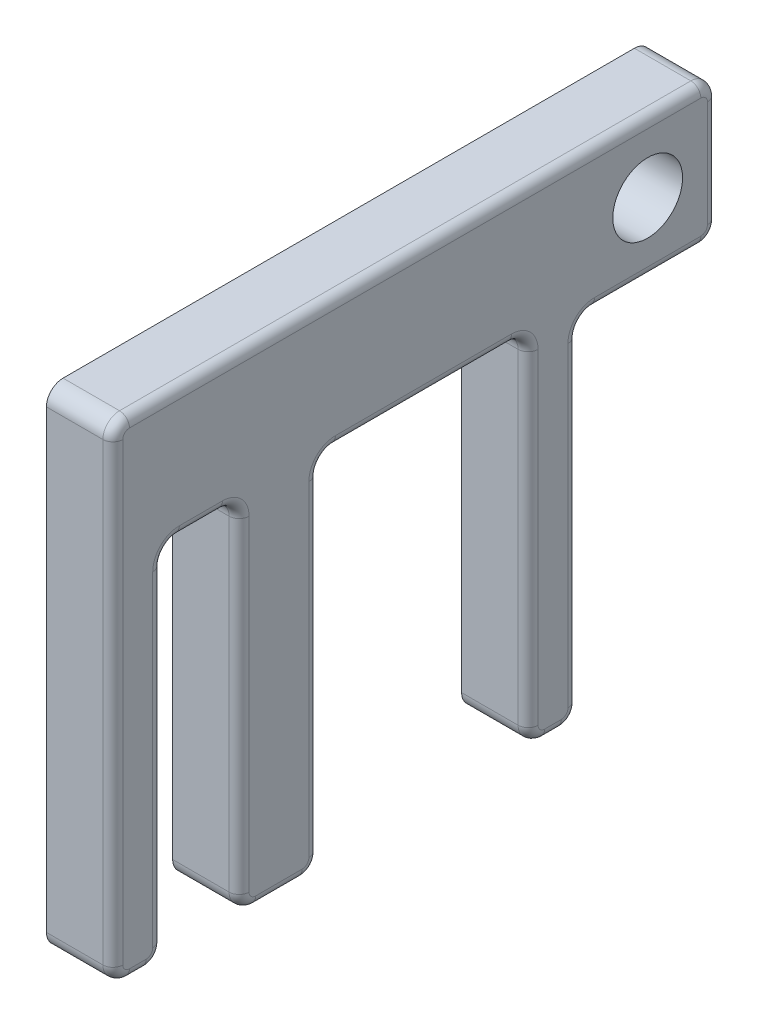
from build123d import *

# Parameters (mm, degrees)
SKETCH2_R           = 2.667
BOSS_EXTRUDE1_DEPTH = 5.08
FILLET1_R           = 1.27
FILLET2_R           = 0.762


with BuildPart() as part:
    # Sketch2 → Boss-Extrude1 (new body)
    with BuildSketch(Plane(origin=(104.932978861, 0, 0), x_dir=(0, 0, -1), z_dir=(1, 0, 0))):
        Polygon((-107.309772969, 81.573572085), (-107.309772969, 65.825572085), (-107.309772969, 60.745572085), (-107.309772969, 44.235572085), (-103.499772969, 44.235572085), (-103.499772969, 46.775572085), (-103.499772969, 71.667572085), (-97.657772969, 71.667572085), (-97.657772969, 46.775572085), (-97.657772969, 44.235572085), (-91.561772969, 44.235572085), (-91.561772969, 46.775572085), (-91.561772969, 71.667572085), (-75.559772969, 71.667572085), (-75.559772969, 46.775572085), (-75.559772969, 44.235572085), (-71.749772969, 44.235572085), (-71.749772969, 70.905572085), (-61.081772969, 70.905572085), (-61.081772969, 81.573572085), align=None)
        with Locations((-66.415772969, 76.239572085)):
            Circle(SKETCH2_R, mode=Mode.SUBTRACT)
    extrude(amount=BOSS_EXTRUDE1_DEPTH)

    # Fillet1
    fillet1_edges = [part.edges().sort_by_distance(p)[0] for p in [
        (107.472978861, 81.573572085, 61.081772969),
        (107.472978861, 70.905572085, 61.081772969),
        (107.472978861, 70.905572085, 71.749772969),
        (107.472978861, 44.235572085, 71.749772969),
        (107.472978861, 44.235572085, 75.559772969),
        (107.472978861, 71.667572085, 75.559772969),
        (107.472978861, 71.667572085, 91.561772969),
        (107.472978861, 44.235572085, 91.561772969),
        (107.472978861, 44.235572085, 97.657772969),
        (107.472978861, 71.667572085, 97.657772969),
        (107.472978861, 71.667572085, 103.499772969),
        (107.472978861, 44.235572085, 103.499772969),
        (107.472978861, 44.235572085, 107.309772969),
        (107.472978861, 81.573572085, 107.309772969),
    ]]
    fillet(fillet1_edges, radius=FILLET1_R)

    # Fillet2
    fillet2_edges = [part.edges().sort_by_distance(p)[0] for p in [
        (110.012978861, 70.533597697, 71.377798581),
        (110.012978861, 57.570572085, 71.749772969),
        (110.012978861, 44.607546473, 72.121747356),
        (110.012978861, 44.235572085, 73.654772969),
        (110.012978861, 44.607546473, 75.187798581),
        (110.012978861, 57.951572085, 75.559772969),
        (110.012978861, 71.295597697, 75.931747356),
        (110.012978861, 71.667572085, 83.560772969),
        (110.012978861, 71.295597697, 91.189798581),
        (110.012978861, 57.951572085, 91.561772969),
        (110.012978861, 44.607546473, 91.933747356),
        (110.012978861, 44.235572085, 94.609772969),
        (110.012978861, 44.607546473, 97.285798581),
        (110.012978861, 57.951572085, 97.657772969),
        (110.012978861, 71.295597697, 98.029747356),
        (110.012978861, 71.667572085, 100.578772969),
        (110.012978861, 71.295597697, 103.127798581),
        (110.012978861, 57.951572085, 103.499772969),
        (110.012978861, 44.607546473, 103.871747356),
        (110.012978861, 44.235572085, 105.404772969),
        (110.012978861, 44.607546473, 106.937798581),
        (110.012978861, 62.904572085, 107.309772969),
        (110.012978861, 81.201597697, 106.937798581),
        (110.012978861, 81.573572085, 84.195772969),
        (110.012978861, 81.201597697, 61.453747356),
        (110.012978861, 76.239572085, 61.081772969),
        (110.012978861, 71.277546473, 61.453747356),
        (110.012978861, 70.905572085, 66.415772969),
    ]]
    fillet(fillet2_edges, radius=FILLET2_R)


solid = part.part
